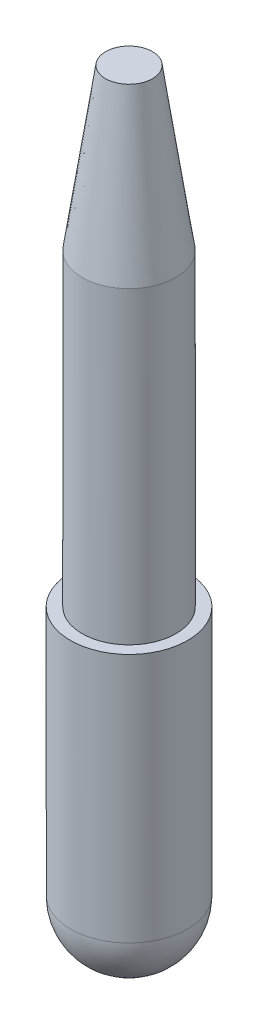
from build123d import *

# Parameters (mm, degrees)
SKETCH1_R      = 3.8
EXTRUDE1_DEPTH = 25
SKETCH2_R      = 4.75
EXTRUDE2_DEPTH = 20.25


with BuildPart() as part:
    # Sketch1 → Extrude1 (new body)
    with BuildSketch(Plane(origin=(0, 0, 0), x_dir=(1, 0, 0), z_dir=(0, 1, 0))):
        Circle(SKETCH1_R)
    extrude(amount=EXTRUDE1_DEPTH)

    # Sketch2 → Extrude2 (add)
    with BuildSketch(Plane.XZ):
        Circle(SKETCH2_R)
    extrude(amount=EXTRUDE2_DEPTH)

    # Sketch3 → Revolve1 (revolve)
    with BuildSketch(Plane(origin=(0, 0, 0), x_dir=(0, 0, -1), z_dir=(1, 0, 0))):
        with BuildLine():
            Line((0, -25), (0, -20.25))
            Line((0, -20.25), (-4.75, -20.25))
            ThreePointArc((-4.75, -20.25), (-3.358757211, -23.608757211), (0, -25))
        make_face()
    revolve(axis=Axis((0, -25.519108832, 0), (0, 1, 0)))

    # Sketch4 → Revolve2 (revolve)
    with BuildSketch(Plane(origin=(0, 0, 0), x_dir=(0, 0, -1), z_dir=(1, 0, 0))):
        Polygon((0, 25), (3.8, 25), (1.9, 38), (0, 38), align=None)
    revolve(axis=Axis((0, 39.39190429, 0), (0, -1, 0)))


solid = part.part
